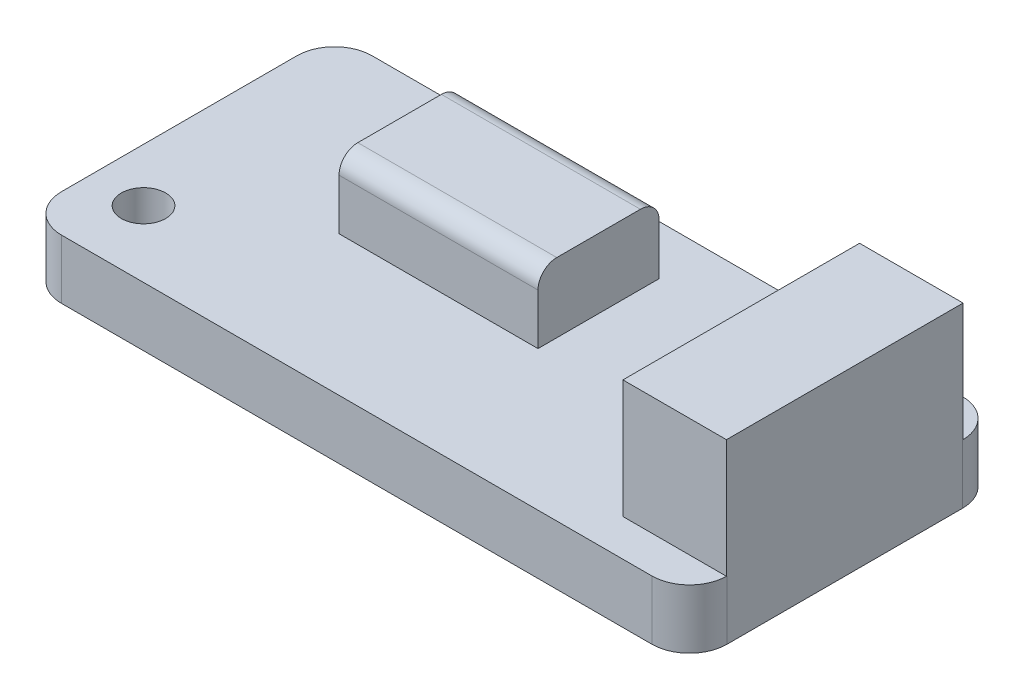
from build123d import *

# Parameters (mm, degrees)
BOSS_EXTRUDE1_DEPTH = 4
SKETCH2_W           = 7
SKETCH2_H           = 16
BOSS_EXTRUDE2_DEPTH = 8
SKETCH3_W           = 13.452288764
SKETCH3_H           = 8.193666793
BOSS_EXTRUDE3_DEPTH = 4.698
FILLET1_R           = 1.27
SKETCH4_R           = 1.5
CUT_EXTRUDE1_DEPTH  = 5


with BuildPart() as part:
    # Sketch1 → Boss-Extrude1 (new body)
    with BuildSketch(Plane(origin=(0, 0, 0), x_dir=(1, 0, 0), z_dir=(0, 1, 0))):
        with BuildLine():
            Line((-19.96, -10.5), (19.96, -10.5))
            ThreePointArc((19.96, -10.5), (21.756051224, -9.756051224), (22.5, -7.96))
            Line((22.5, -7.96), (22.5, 7.96))
            ThreePointArc((22.5, 7.96), (21.756051224, 9.756051224), (19.96, 10.5))
            Line((19.96, 10.5), (-19.96, 10.5))
            ThreePointArc((-19.96, 10.5), (-21.756051224, 9.756051224), (-22.5, 7.96))
            Line((-22.5, 7.96), (-22.5, -7.96))
            ThreePointArc((-22.5, -7.96), (-21.756051224, -9.756051224), (-19.96, -10.5))
        make_face()
    extrude(amount=BOSS_EXTRUDE1_DEPTH)

    # Sketch2 → Boss-Extrude2 (add)
    with BuildSketch(Plane(origin=(0, 4, 0), x_dir=(1, 0, 0), z_dir=(0, 1, 0))):
        with Locations((19, 0)):
            Rectangle(SKETCH2_W, SKETCH2_H)
    extrude(amount=BOSS_EXTRUDE2_DEPTH)

    # Sketch3 → Boss-Extrude3 (add)
    with BuildSketch(Plane(origin=(0, 4, 0), x_dir=(1, 0, 0), z_dir=(0, 1, 0))):
        with Locations((-3.928679787, 3.057338356)):
            Rectangle(SKETCH3_W, SKETCH3_H)
    extrude(amount=BOSS_EXTRUDE3_DEPTH)

    # Fillet1
    fillet1_edges = [part.edges().sort_by_distance(p)[0] for p in [
        (-3.928679787, 8.698, 1.039495041),
        (-3.928679787, 8.698, -7.154171752),
    ]]
    fillet(fillet1_edges, radius=FILLET1_R)

    # Sketch4 → Cut-Extrude1 (cut, through all)
    with BuildSketch(Plane(origin=(0, 4, 0), x_dir=(1, 0, 0), z_dir=(0, 1, 0))):
        with Locations((-18.902, -6.01)):
            Circle(SKETCH4_R)
        with Locations((10.308, 6.69)):
            Circle(SKETCH4_R)
    extrude(amount=-CUT_EXTRUDE1_DEPTH, mode=Mode.SUBTRACT)


solid = part.part
